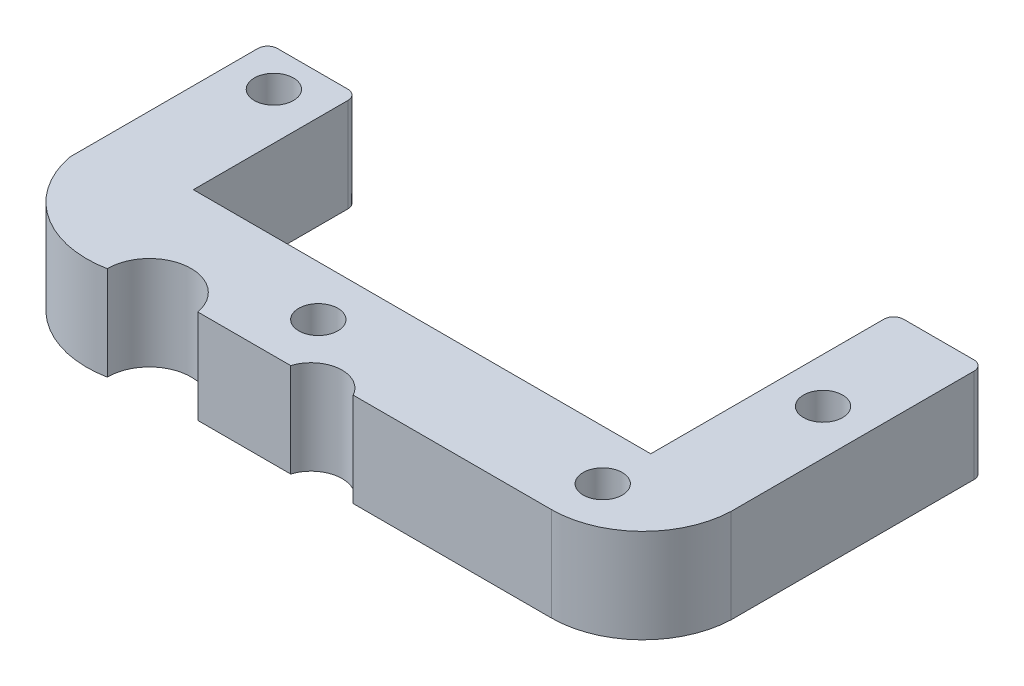
from build123d import *

# Parameters (mm, degrees)
SKETCH1_R           = 1
BOSS_EXTRUDE1_DEPTH = 4.8
FILLET1_R           = 0.5


with BuildPart() as part:
    # Sketch1 → Boss-Extrude1 (new body)
    with BuildSketch(Plane(origin=(0, 0, 0), x_dir=(1, 0, 0), z_dir=(0, 1, 0))):
        with BuildLine():
            Line((0, 0), (0, 10.109966322))
            Line((0, 10.109966322), (4.6, 10.109966322))
            Line((4.6, 10.109966322), (4.6, 1.714229872))
            Line((4.6, 1.714229872), (27.967443814, 1.714229872))
            Line((27.967443814, 1.714229872), (27.967443814, 14.126132931))
            Line((27.967443814, 14.126132931), (32.567443814, 14.126132931))
            Line((32.567443814, 14.126132931), (32.567443814, 1.22414249))
            ThreePointArc((32.567443814, 1.22414249), (31.144234193, -1.974320184), (27.900175322, -3.290287941))
            Line((27.900175322, -3.290287941), (17.770133396, -3.290287941))
            ThreePointArc((17.770133396, -3.290287941), (16.223398412, -2.475294407), (14.868870839, -3.580671549))
            Line((14.868870839, -3.580671549), (10.12183502, -3.580671549))
            ThreePointArc((10.12183502, -3.580671549), (7.826617972, -1.836209825), (5.897335796, -3.978413896))
            ThreePointArc((5.897335796, -3.978413896), (2.124711402, -3.210585182), (0, 0))
        make_face()
        with Locations((28.067931627, -0.839685826)):
            Circle(SKETCH1_R, mode=Mode.SUBTRACT)
        with Locations((30.267443814, 8.215801601)):
            Circle(SKETCH1_R, mode=Mode.SUBTRACT)
        with Locations((2.212966765, 8.215801601)):
            Circle(SKETCH1_R, mode=Mode.SUBTRACT)
        with Locations((13.539270752, -0.839685826)):
            Circle(SKETCH1_R, mode=Mode.SUBTRACT)
    extrude(amount=BOSS_EXTRUDE1_DEPTH)

    # Fillet1
    fillet1_edges = [part.edges().sort_by_distance(p)[0] for p in [
        (27.967443814, 2.4, -14.126132931),
        (32.567443814, 2.4, -14.126132931),
        (0, 2.4, -10.109966322),
        (4.6, 2.4, -10.109966322),
    ]]
    fillet(fillet1_edges, radius=FILLET1_R)


solid = part.part
